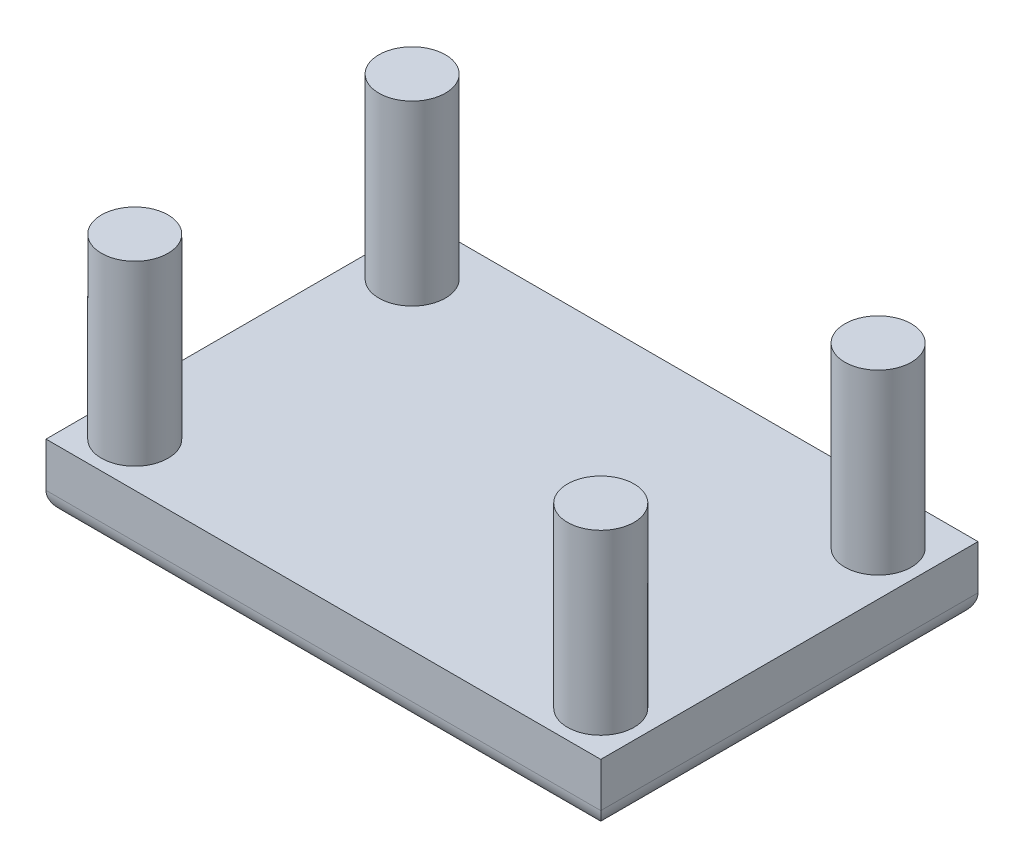
from build123d import *

# Parameters (mm, degrees)
SKETCH1_W           = 25
SKETCH1_H           = 17
BOSS_EXTRUDE1_DEPTH = 3
SKETCH2_R           = 1.5
BOSS_EXTRUDE2_DEPTH = 8
FILLET3_R           = 1


with BuildPart() as part:
    # Sketch1 → Boss-Extrude1 (new body)
    with BuildSketch(Plane(origin=(0, 0, 0), x_dir=(1, 0, 0), z_dir=(0, 1, 0))):
        Rectangle(SKETCH1_W, SKETCH1_H)
    extrude(amount=BOSS_EXTRUDE1_DEPTH)

    # Sketch2 → Boss-Extrude2 (add)
    with BuildSketch(Plane(origin=(0, 3, 0), x_dir=(1, 0, 0), z_dir=(0, 1, 0))):
        with Locations((-10.5, -6.5)):
            Circle(SKETCH2_R)
        with Locations((10.5, -6.5)):
            Circle(SKETCH2_R)
        with Locations((10.5, 5.999999892)):
            Circle(SKETCH2_R)
        with Locations((-10.5, 5.999999892)):
            Circle(SKETCH2_R)
    extrude(amount=BOSS_EXTRUDE2_DEPTH)

    # Fillet3
    fillet3_edges = [part.edges().sort_by_distance(p)[0] for p in [
        (0, 0, 8.5),
        (-12.5, 0, 0),
        (0, 0, -8.5),
        (12.5, 0, 0),
    ]]
    fillet(fillet3_edges, radius=FILLET3_R)


solid = part.part
